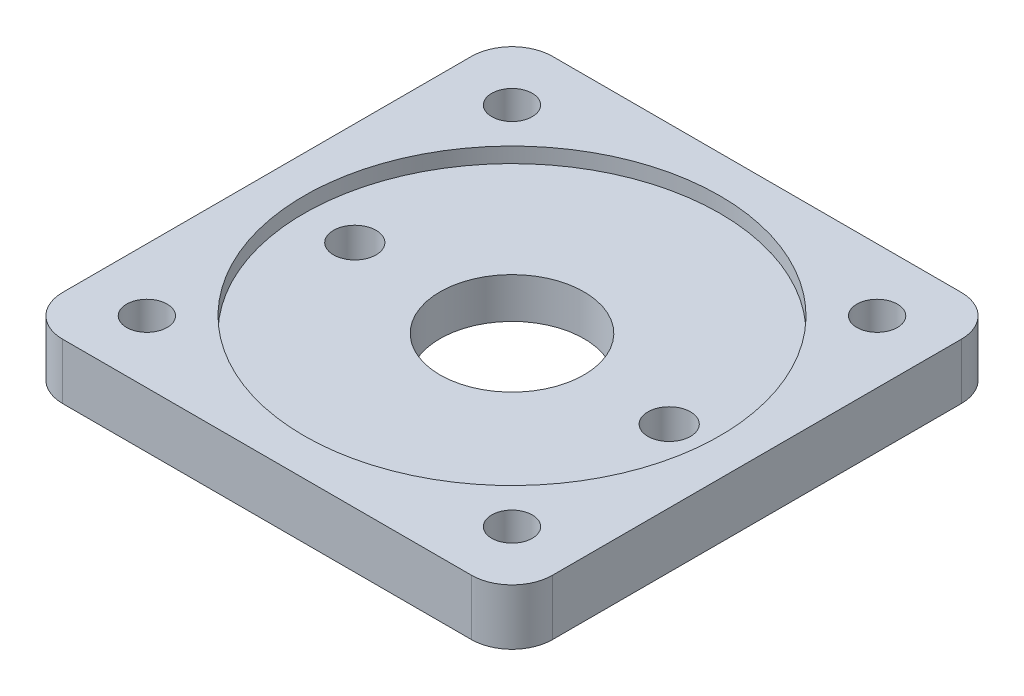
from build123d import *

# Parameters (mm, degrees)
IZIM2_R                     = 7.1
IZIM2_R_2                   = 2
IZIM2_R_3                   = 2.1
Y_KSEKLIK_EKSTR_ZYON1_DEPTH = 5.5
IZIM3_R                     = 20.5
KES_EKSTR_ZYON1_DEPTH       = 1.5


with BuildPart() as part:
    # Çizim2 → Yükseklik-Ekstrüzyon1 (new body)
    with BuildSketch(Plane(origin=(0, 0, 0), x_dir=(1, 0, 0), z_dir=(0, 1, 0))):
        with BuildLine():
            Line((-20.15, -24.15), (20.15, -24.15))
            ThreePointArc((20.15, -24.15), (22.978427125, -22.978427125), (24.15, -20.15))
            Line((24.15, -20.15), (24.15, 20.15))
            ThreePointArc((24.15, 20.15), (22.978427125, 22.978427125), (20.15, 24.15))
            Line((20.15, 24.15), (-20.15, 24.15))
            ThreePointArc((-20.15, 24.15), (-22.978427125, 22.978427125), (-24.15, 20.15))
            Line((-24.15, 20.15), (-24.15, -20.15))
            ThreePointArc((-24.15, -20.15), (-22.978427125, -22.978427125), (-20.15, -24.15))
        make_face()
        Circle(IZIM2_R, mode=Mode.SUBTRACT)
        with Locations((-18, 18)):
            Circle(IZIM2_R_2, mode=Mode.SUBTRACT)
        with Locations((18, 18)):
            Circle(IZIM2_R_2, mode=Mode.SUBTRACT)
        with Locations((-18, -18)):
            Circle(IZIM2_R_2, mode=Mode.SUBTRACT)
        with Locations((18, -18)):
            Circle(IZIM2_R_2, mode=Mode.SUBTRACT)
        with Locations((-15.5, 0)):
            Circle(IZIM2_R_3, mode=Mode.SUBTRACT)
        with Locations((15.5, 0)):
            Circle(IZIM2_R_3, mode=Mode.SUBTRACT)
    extrude(amount=Y_KSEKLIK_EKSTR_ZYON1_DEPTH)

    # Çizim3 → Kes-Ekstrüzyon1 (cut)
    with BuildSketch(Plane(origin=(0, 5.5, 0), x_dir=(1, 0, 0), z_dir=(0, 1, 0))):
        Circle(IZIM3_R)
    extrude(amount=-KES_EKSTR_ZYON1_DEPTH, mode=Mode.SUBTRACT)


solid = part.part
